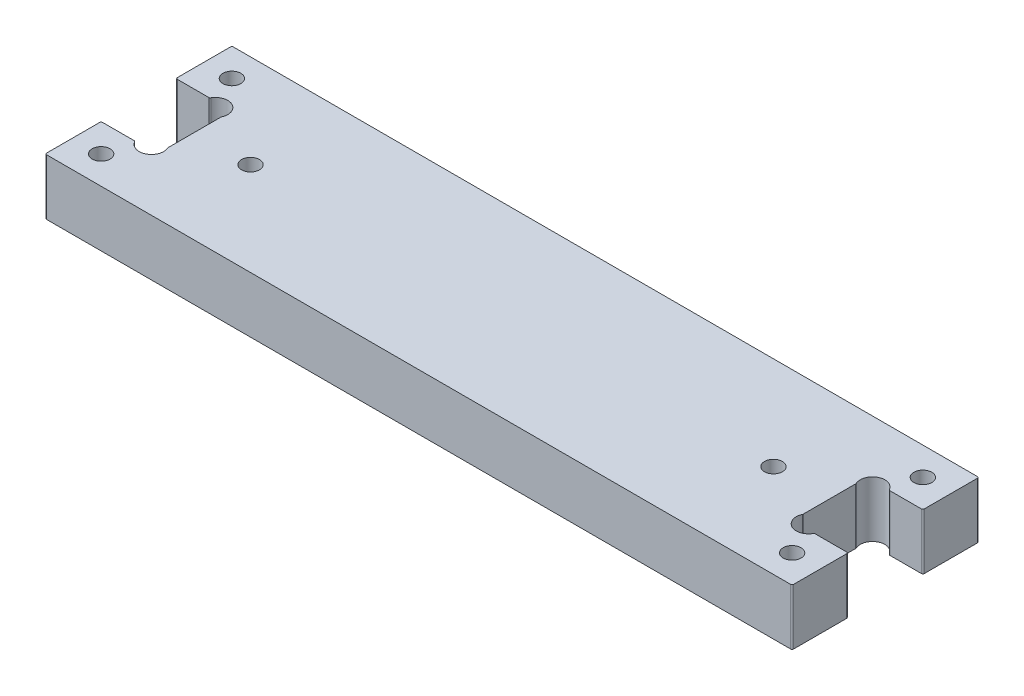
from build123d import *

# Parameters (mm, degrees)
SKETCH1_W           = 107.95
SKETCH1_H           = 25.4
BOSS_EXTRUDE1_DEPTH = 9.525
SKETCH3_W           = 107.95
SKETCH3_H           = 6.35
CUT_EXTRUDE2_DEPTH  = 10.525
SKETCH5_R           = 1.524
CUT_EXTRUDE4_DEPTH  = 10.525
SKETCH6_W           = 107.95
SKETCH6_H           = 6.35
BOSS_EXTRUDE2_DEPTH = 9.525
SKETCH7_W           = 9.525
SKETCH7_H           = 9.525
SKETCH7_R           = 1.524
BOSS_EXTRUDE3_DEPTH = 9.525
SKETCH8_R           = 2.0955
CUT_EXTRUDE5_DEPTH  = 10.525
FILLET3_R           = 0.254


with BuildPart() as part:
    # Sketch1 → Boss-Extrude1 (new body)
    with BuildSketch(Plane(origin=(0, 0, 0), x_dir=(1, 0, 0), z_dir=(0, 1, 0))):
        Rectangle(SKETCH1_W, SKETCH1_H)
    extrude(amount=BOSS_EXTRUDE1_DEPTH)

    # Sketch3 → Cut-Extrude2 (cut, through all)
    with BuildSketch(Plane.XZ):
        with Locations((0, 9.525)):
            Rectangle(SKETCH3_W, SKETCH3_H)
    extrude(amount=-CUT_EXTRUDE2_DEPTH, mode=Mode.SUBTRACT)

    # Sketch5 → Cut-Extrude4 (cut, through all)
    with BuildSketch(Plane(origin=(0, 9.525, 0), x_dir=(1, 0, 0), z_dir=(0, 1, 0))):
        with Locations((44.45, 3.175)):
            Circle(SKETCH5_R)
        with Locations((-44.45, 3.175)):
            Circle(SKETCH5_R)
    extrude(amount=-CUT_EXTRUDE4_DEPTH, mode=Mode.SUBTRACT)

    # Sketch6 → Boss-Extrude2 (add, through all)
    with BuildSketch(Plane(origin=(0, 9.525, 0), x_dir=(1, 0, 0), z_dir=(0, 1, 0))):
        with Locations((0, 15.875)):
            Rectangle(SKETCH6_W, SKETCH6_H)
        with Locations((0, -9.525)):
            Rectangle(SKETCH6_W, SKETCH6_H)
    extrude(amount=-BOSS_EXTRUDE2_DEPTH)

    # Sketch7 → Boss-Extrude3 (add, through all)
    with BuildSketch(Plane(origin=(0, 9.525, 0), x_dir=(1, 0, 0), z_dir=(0, 1, 0))):
        with Locations((58.7375, 14.2875)):
            Rectangle(SKETCH7_W, SKETCH7_H)
        with Locations((58.7375, 14.2875)):
            Circle(SKETCH7_R, mode=Mode.SUBTRACT)
        with Locations((58.7375, -7.9375)):
            Rectangle(SKETCH7_W, SKETCH7_H)
        with Locations((58.7375, -7.9375)):
            Circle(SKETCH7_R, mode=Mode.SUBTRACT)
        with Locations((-58.7375, -7.9375)):
            Rectangle(SKETCH7_W, SKETCH7_H)
        with Locations((-58.7375, -7.9375)):
            Circle(SKETCH7_R, mode=Mode.SUBTRACT)
        with Locations((-58.7375, 14.2875)):
            Rectangle(SKETCH7_W, SKETCH7_H)
        with Locations((-58.7375, 14.2875)):
            Circle(SKETCH7_R, mode=Mode.SUBTRACT)
    extrude(amount=-BOSS_EXTRUDE3_DEPTH)

    # Sketch8 → Cut-Extrude5 (cut, through all)
    with BuildSketch(Plane(origin=(0, 0, 0), x_dir=(-1, 0, 0), z_dir=(0, -1, 0))):
        with Locations((55.860468878, -2.2606)):
            Circle(SKETCH8_R)
        with Locations((55.860468878, 8.6106)):
            Circle(SKETCH8_R)
    cut_extrude5 = extrude(amount=-CUT_EXTRUDE5_DEPTH, mode=Mode.SUBTRACT)

    # Mirror1: Cut-Extrude5 across plane
    add(cut_extrude5.mirror(Plane(origin=(0, 0, 0), x_dir=(0, 0, 1), z_dir=(1, 0, 0))), mode=Mode.SUBTRACT)

    # Fillet3
    fillet3_edges = [part.edges().sort_by_distance(p)[0] for p in [
        (-63.5, 4.7625, -9.525),
        (-63.5, 4.7625, -19.05),
        (-57.745937756, 4.7625, -9.525),
        (-57.745937756, 4.7625, 3.175),
        (-53.975, 4.7625, 1.3462),
        (-53.975, 4.7625, -7.6962),
        (57.745937756, 4.7625, 3.175),
        (57.745937756, 4.7625, -9.525),
        (53.975, 4.7625, 1.3462),
        (53.975, 4.7625, -7.6962),
        (63.5, 4.7625, -19.05),
        (63.5, 4.7625, -9.525),
        (63.5, 4.7625, 3.175),
        (63.5, 4.7625, 12.7),
        (-63.5, 4.7625, 12.7),
        (-63.5, 4.7625, 3.175),
    ]]
    fillet(fillet3_edges, radius=FILLET3_R)


solid = part.part
